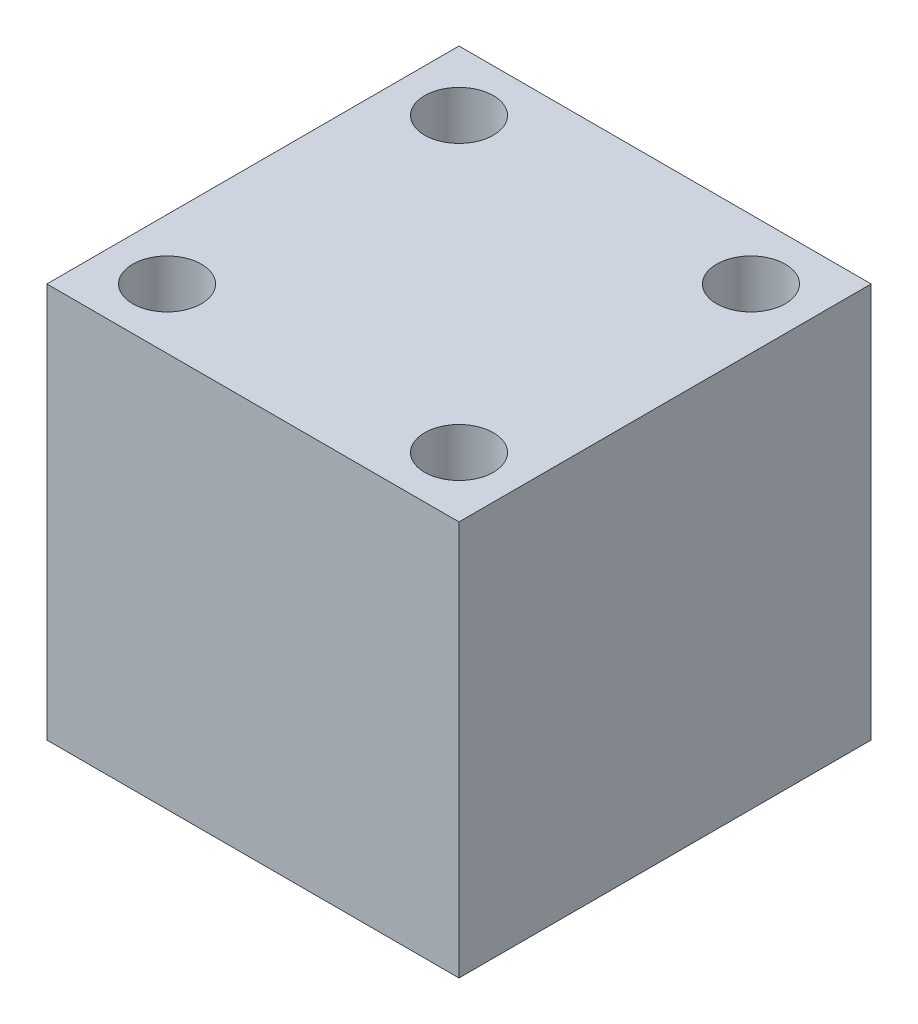
from build123d import *

# Parameters (mm, degrees)
EXTRUDE_START       = -29
SKETCH_1_W          = 36
SKETCH_1_H          = 34.5
EXTRUDE_1_DEPTH     = 36
SKETCH_2_R          = 3
CUT_EXTRUDE_1_DEPTH = 5


with BuildPart() as part:
    # ｽｹｯﾁ1 → ﾎﾞｽ - 押し出し1 (new body)
    with BuildSketch(Plane.XY.offset(EXTRUDE_START)):
        with Locations((18, -23.029537634)):
            Rectangle(SKETCH_1_W, SKETCH_1_H)
    extrude(amount=EXTRUDE_1_DEPTH)

    # ｽｹｯﾁ2 → ｶｯﾄ - 押し出し1 (cut)
    with BuildSketch(Plane(origin=(0, -5.779537634, 0), x_dir=(1, 0, 0), z_dir=(0, 1, 0))):
        with Locations((30.75, 23.75)):
            Circle(SKETCH_2_R)
        with Locations((30.75, -1.75)):
            Circle(SKETCH_2_R)
        with Locations((5.25, -1.75)):
            Circle(SKETCH_2_R)
        with Locations((5.25, 23.75)):
            Circle(SKETCH_2_R)
    extrude(amount=-CUT_EXTRUDE_1_DEPTH, mode=Mode.SUBTRACT)


solid = part.part
